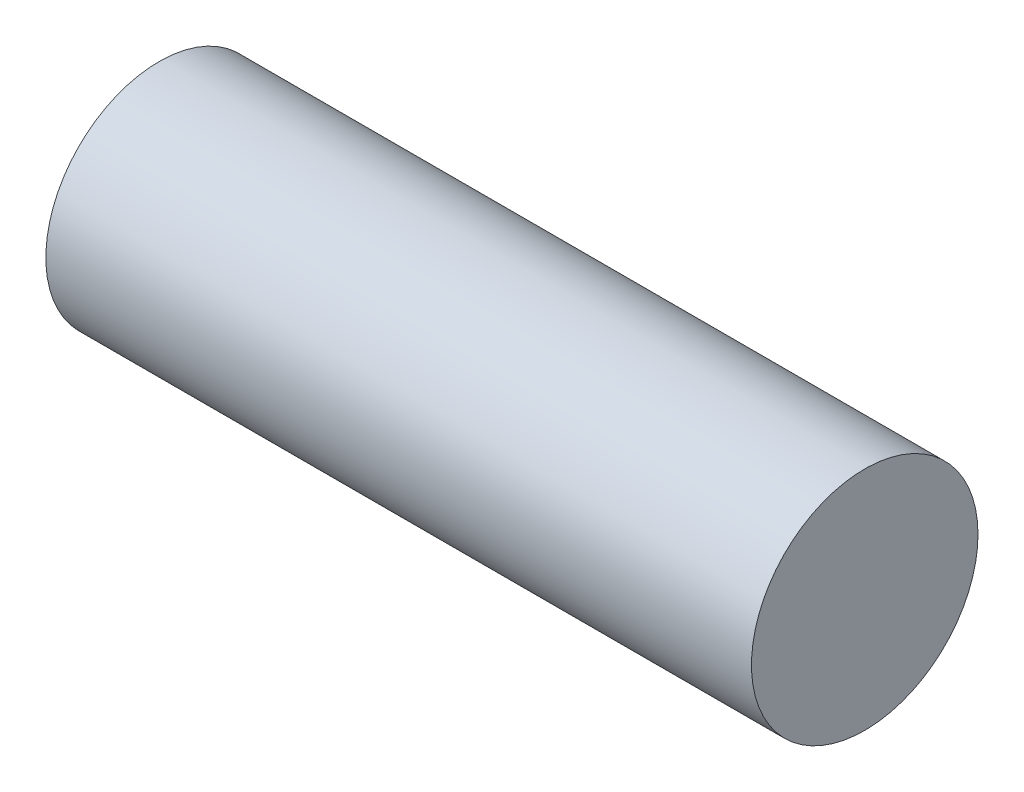
from build123d import *

# Parameters (mm, degrees)
ESQUISSE1_R             = 16.1
BOSS_EXTRU_1_DEPTH      = 100.3
ESQUISSE2_W             = 10
ESQUISSE2_H             = 5
ENL_V_MAT_EXTRU_1_DEPTH = 10
ENL_V_MAT_EXTRU_2_DEPTH = 10


with BuildPart() as part:
    # Esquisse1 → Boss.-Extru.1 (new body)
    with BuildSketch(Plane(origin=(0, 0, 0), x_dir=(0, 0, -1), z_dir=(1, 0, 0))):
        Circle(ESQUISSE1_R)
    extrude(amount=BOSS_EXTRU_1_DEPTH)

    # Esquisse2 → Enlèv. mat.-Extru.1 (cut)
    with BuildSketch(Plane.ZY):
        with Locations((-4, 0.220705936)):
            Rectangle(ESQUISSE2_W, ESQUISSE2_H)
    extrude(amount=-ENL_V_MAT_EXTRU_1_DEPTH, mode=Mode.SUBTRACT)

    # Esquisse3 → Enlèv. mat.-Extru.2 (cut)
    with BuildSketch(Plane.ZY):
        with BuildLine():
            Line((3.990495341, -1.5), (11.990495341, -1.5))
            ThreePointArc((11.990495341, -1.5), (11.301155513, -0.335786438), (9.990495341, 0))
            Line((9.990495341, 0), (5.990495341, 0))
            ThreePointArc((5.990495341, 0), (4.679835169, -0.335786438), (3.990495341, -1.5))
        make_face()
    extrude(amount=-ENL_V_MAT_EXTRU_2_DEPTH, mode=Mode.SUBTRACT)


solid = part.part
